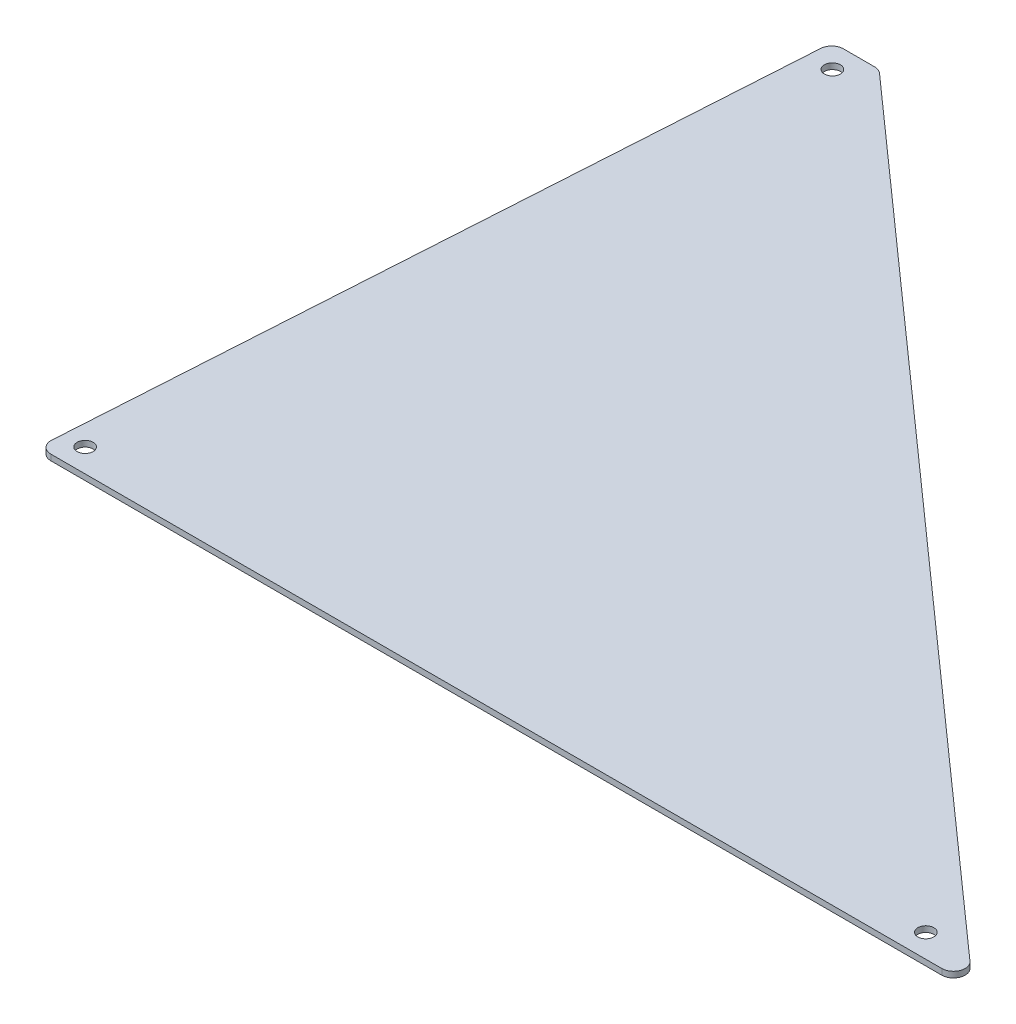
from build123d import *

# Parameters (mm, degrees)
SKETCH1_R           = 2.1828125
BOSS_EXTRUDE1_DEPTH = 1.5875


with BuildPart() as part:
    # Sketch1 → Boss-Extrude1 (new body)
    with BuildSketch(Plane(origin=(0, 0, 0), x_dir=(1, 0, 0), z_dir=(0, 1, 0))):
        with BuildLine():
            Line((3.379632628, 0), (245.649117152, 0))
            ThreePointArc((245.649117152, 0), (248.616858554, 2.04666673), (247.75847234, 5.548024587))
            Line((247.75847234, 5.548024587), (26.30222234, 202.398024587))
            ThreePointArc((26.30222234, 202.398024587), (25.321200422, 202.992741402), (24.192867152, 203.2))
            Line((24.192867152, 203.2), (15.682757628, 203.2))
            ThreePointArc((15.682757628, 203.2), (13.508842624, 202.339026481), (12.513940691, 200.223051059))
            Line((12.513940691, 200.223051059), (0.210815691, 3.373051059))
            ThreePointArc((0.210815691, 3.373051059), (1.065606147, 1.001084996), (3.379632628, 0))
        make_face()
        with Locations((234.95, 6.35)):
            Circle(SKETCH1_R, mode=Mode.SUBTRACT)
        with Locations((6.35, 6.35)):
            Circle(SKETCH1_R, mode=Mode.SUBTRACT)
        with Locations((19.05, 196.85)):
            Circle(SKETCH1_R, mode=Mode.SUBTRACT)
    extrude(amount=BOSS_EXTRUDE1_DEPTH)


solid = part.part
